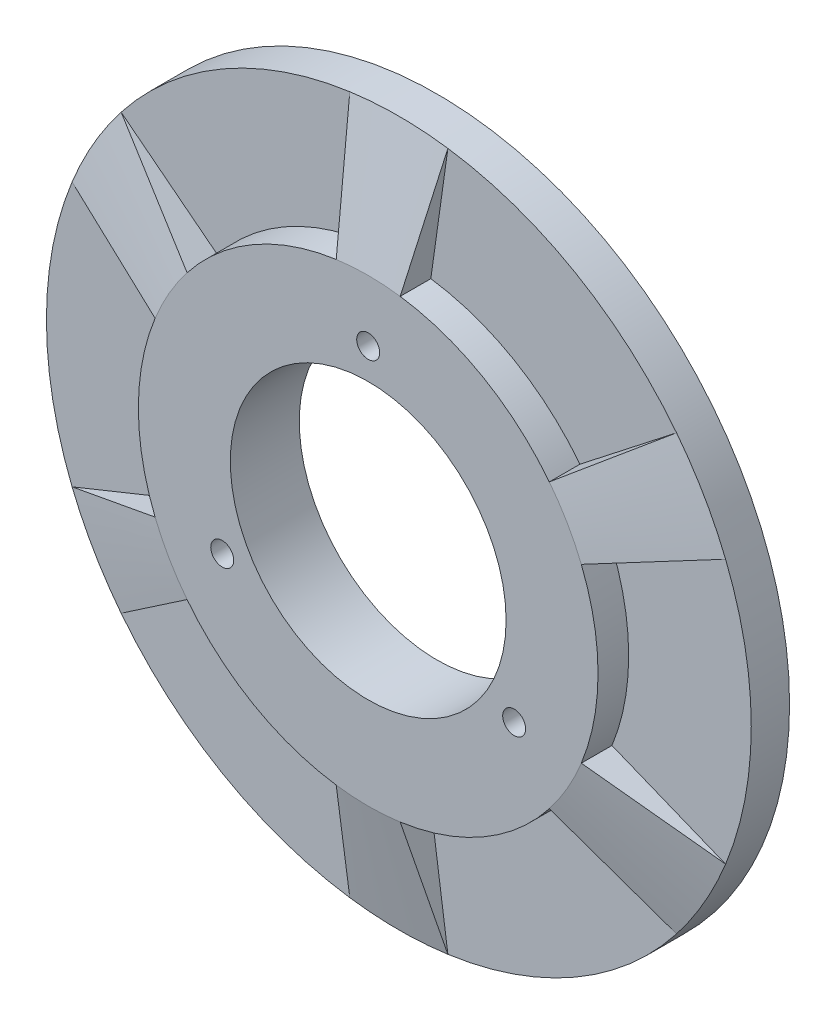
from build123d import *

# Parameters (mm, degrees)
SKETCH2_R               = 46
SKETCH2_R_2             = 18
BOSS_EXTRUDE2_DEPTH     = 5
SKETCH4_R               = 30
SKETCH4_R_2             = 18
BOSS_EXTRUDE3_DEPTH     = 4
SKETCH5_R               = 1.5
CUT_EXTRUDE1_DEPTH      = 66.673434507
CUT_EXTRUDE1_DEPTH_BACK = 66.673434507
REVOLVE1_ANGLE          = 16
CIRPATTERN1_COUNT       = 6


with BuildPart() as part:
    # Sketch2 → Boss-Extrude2 (new body)
    with BuildSketch(Plane.XY):
        Circle(SKETCH2_R)
        Circle(SKETCH2_R_2, mode=Mode.SUBTRACT)
    extrude(amount=BOSS_EXTRUDE2_DEPTH)

    # Sketch4 → Boss-Extrude3 (add)
    with BuildSketch(Plane.XY.offset(5)):
        Circle(SKETCH4_R)
        Circle(SKETCH4_R_2, mode=Mode.SUBTRACT)
    extrude(amount=BOSS_EXTRUDE3_DEPTH)

    # Sketch5 → Cut-Extrude1 (cut, two sides)
    with BuildSketch(Plane(origin=(0, 0, 0), x_dir=(-1, 0, 0), z_dir=(0, 0, -1))) as cut_extrude1_sk:
        with Locations((0, 22)):
            Circle(SKETCH5_R)
        with Locations((19.052558883, -11)):
            Circle(SKETCH5_R)
        with Locations((-19.052558883, -11)):
            Circle(SKETCH5_R)
    extrude(amount=CUT_EXTRUDE1_DEPTH, mode=Mode.SUBTRACT)
    extrude(cut_extrude1_sk.sketch, amount=-CUT_EXTRUDE1_DEPTH_BACK, mode=Mode.SUBTRACT)

    # Sketch6 → Revolve1 (revolve, symmetric)
    with BuildSketch(Plane(origin=(0, 0, 0), x_dir=(0, 0, -1), z_dir=(1, 0, 0))) as revolve1_sk:
        Polygon((-5, 30), (-9, 30), (-5, 46), align=None)
    revolve1 = revolve(axis=Axis((0, 0, 0), (0, 0, -1)), revolution_arc=REVOLVE1_ANGLE / 2)
    revolve1 = revolve1 + revolve(revolve1_sk.sketch, axis=Axis((0, 0, 0), (0, 0, 1)), revolution_arc=REVOLVE1_ANGLE / 2)

    # CirPattern1: Revolve1 ×6 about axis
    cirpattern1_axis = Axis((0, 0, 0), (0, 0, 1))
    for i in range(1, CIRPATTERN1_COUNT):
        add(revolve1.rotate(cirpattern1_axis, i * 360 / CIRPATTERN1_COUNT))


solid = part.part
